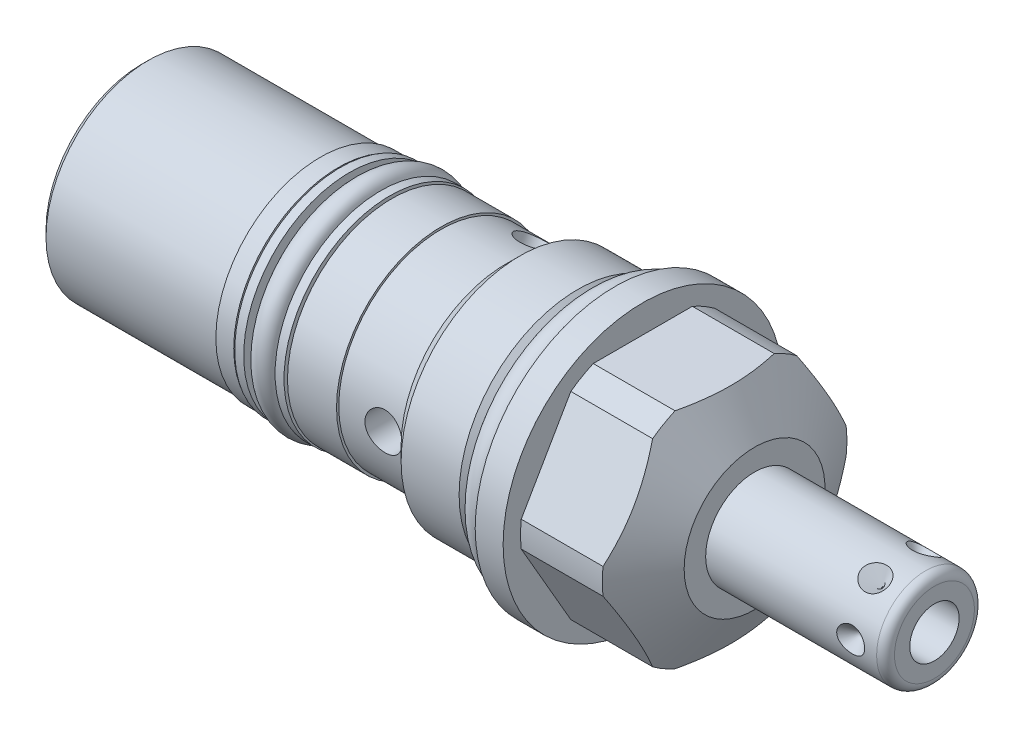
from build123d import *

# Parameters (mm, degrees)
SKETCH2_OUTSIDE_W  = 50.328
SKETCH2_OUTSIDE_H  = 50.328
CUT_EXTRUDE1_DEPTH = 12.7
CIRPATTERN1_COUNT  = 6
SKETCH6_W          = 13.716
SKETCH6_H          = 0.254
SKETCH7_R          = 0.8001
CUT_EXTRUDE2_DEPTH = 0.762
SKETCH8_W          = 6.1087
SKETCH8_H          = 2.0447
SKETCH9_W          = 1.016
SKETCH9_H          = 2.1844
SKETCH10_W         = 2.1082
SKETCH10_H         = 10.82675
CIRPATTERN2_COUNT  = 3
CHAMFER1_SIZE      = 0.762
SKETCH11_R         = 1.4732
SKETCH12_R         = 1.3081


with BuildPart() as part:
    # Sketch1 → Revolve1 (revolve)
    with BuildSketch(Plane.XY, mode=Mode.PRIVATE) as revolve1_sk:
        Polygon((0, 15.875), (3.175, 15.875), (3.175, 13.8938), (12.472790334, 13.8938), (15.875, 8.001), (15.875, 0), (-53.7972, 0), (-53.7972, 11.6205), (-12.4206, 11.6205), (-12.4206, 11.8745), (-10.80135, 13.49375), (-4.21005, 13.49375), (-2.7178, 12.0015), (0, 12.0015), align=None)
    revolve(revolve1_sk.sketch.rotate(Axis((0, 0, 0), (1, 0, 0)), 90), axis=Axis((0, 0, 0), (1, 0, 0)))  # turned: the seam where the file's is

    # Sketch2 outside → Cut-Extrude1 (cut)
    with BuildSketch(Plane(origin=(15.875, 0, 0), x_dir=(0, 0, -1), z_dir=(1, 0, 0))):
        Rectangle(SKETCH2_OUTSIDE_W, SKETCH2_OUTSIDE_H)
        Polygon((7.332348419, 12.7), (-7.332348419, 12.7), (-14.664696837, 0), (-7.332348419, -12.7), (7.332348419, -12.7), (14.664696837, 0), align=None, mode=Mode.SUBTRACT)
    extrude(amount=-CUT_EXTRUDE1_DEPTH, mode=Mode.SUBTRACT)

    # Sketch3 → Revolve2 (revolve)
    with BuildSketch(Plane.XY, mode=Mode.PRIVATE) as revolve2_sk:
        with BuildLine():
            Line((15.875, 5.55625), (35.306, 5.55625))
            ThreePointArc((35.306, 5.55625), (36.02442049, 5.25867049), (36.322, 4.54025))
            Line((36.322, 4.54025), (36.322, 0))
            Line((36.322, 0), (15.875, 0))
            Line((15.875, 0), (15.875, 5.55625))
        make_face()
    revolve(revolve2_sk.sketch.rotate(Axis((0, 0, 0), (1, 0, 0)), 90), axis=Axis((0, 0, 0), (1, 0, 0)))  # turned: the seam where the file's is

    # Sketch4 → Cut-Revolve1 (revolve, cut)
    with BuildSketch(Plane(origin=(0, 0, 0), x_dir=(1, 0, 0), z_dir=(0, 1, 0)), mode=Mode.PRIVATE) as cut_revolve1_sk:
        Polygon((33.9471, 5.55625), (32.3596, 5.55625), (32.3596, 3.96875), align=None)
    cut_revolve1 = revolve(cut_revolve1_sk.sketch.rotate(Axis((32.3596, 0, -10.073804773), (0, 0, 1)), 180), axis=Axis((32.3596, 0, -10.073804773), (0, 0, 1)), mode=Mode.SUBTRACT)  # turned: the seam where the file's is

    # CirPattern1: Cut-Revolve1 ×6 about axis
    cirpattern1_axis = Axis((0, 0, 0), (-1, 0, 0))
    for i in range(1, CIRPATTERN1_COUNT):
        add(cut_revolve1.rotate(cirpattern1_axis, i * 360 / CIRPATTERN1_COUNT), mode=Mode.SUBTRACT)

    # Sketch5 → Cut-Revolve2 (revolve, cut)
    with BuildSketch(Plane.XY, mode=Mode.PRIVATE) as cut_revolve2_sk:
        Polygon((36.322, 2.8067), (26.162, 2.8067), (24.475564501, 0), (36.322, 0), align=None)
    revolve(cut_revolve2_sk.sketch.rotate(Axis((0, 0, 0), (1, 0, 0)), 90), axis=Axis((0, 0, 0), (1, 0, 0)), mode=Mode.SUBTRACT)  # turned: the seam where the file's is

    # Sketch6 → Revolve3 (revolve)
    with BuildSketch(Plane.XY, mode=Mode.PRIVATE) as revolve3_sk:
        with Locations((-26.6192, 11.7475)):
            Rectangle(SKETCH6_W, SKETCH6_H)
    revolve(revolve3_sk.sketch.rotate(Axis((0, 0, 0), (-1, 0, 0)), 270), axis=Axis((0, 0, 0), (-1, 0, 0)))  # turned: the seam where the file's is

    # Sketch7 → Cut-Extrude2 (cut)
    with BuildSketch(Plane.ZY.offset(53.7972)):
        Circle(SKETCH7_R)
    extrude(amount=-CUT_EXTRUDE2_DEPTH, mode=Mode.SUBTRACT)

    # Sketch8 → Cut-Revolve3 (revolve, cut)
    with BuildSketch(Plane.XY, mode=Mode.PRIVATE) as cut_revolve3_sk:
        with Locations((-28.39085, 10.85215)):
            Rectangle(SKETCH8_W, SKETCH8_H)
    revolve(cut_revolve3_sk.sketch.rotate(Axis((0, 0, 0), (-1, 0, 0)), 270), axis=Axis((0, 0, 0), (-1, 0, 0)), mode=Mode.SUBTRACT)  # turned: the seam where the file's is

    # Sketch9 → Revolve4 (revolve)
    with BuildSketch(Plane.XY, mode=Mode.PRIVATE) as revolve4_sk:
        with Locations((-26.0985, 10.922)):
            Rectangle(SKETCH9_W, SKETCH9_H)
        with Locations((-30.6832, 10.922)):
            Rectangle(SKETCH9_W, SKETCH9_H)
    revolve(revolve4_sk.sketch.rotate(Axis((0, 0, 0), (-1, 0, 0)), 270), axis=Axis((0, 0, 0), (-1, 0, 0)))  # turned: the seam where the file's is

    # Sketch10 → Cut-Revolve4 (revolve, cut)
    with BuildSketch(Plane(origin=(0, 0, 0), x_dir=(1, 0, 0), z_dir=(0, 1, 0))):
        with Locations((-15.7353, -6.207125)):
            Rectangle(SKETCH10_W, SKETCH10_H)
    cut_revolve4 = revolve(axis=Axis((-14.6812, 0, -23.036850257), (0, 0, 1)), mode=Mode.SUBTRACT)

    # CirPattern2: Cut-Revolve4 ×3 about axis
    cirpattern2_axis = Axis((0, 0, 0), (1, 0, 0))
    for i in range(1, CIRPATTERN2_COUNT):
        add(cut_revolve4.rotate(cirpattern2_axis, i * 360 / CIRPATTERN2_COUNT), mode=Mode.SUBTRACT)

    # Chamfer1
    chamfer1_edges = [part.edges().sort_by_distance(p)[0] for p in [
        (-53.7972, 0, -11.6205),
    ]]
    chamfer(chamfer1_edges, length=CHAMFER1_SIZE)


with BuildPart() as body_2:
    # Sketch11 → Revolve5 (revolve)
    with BuildSketch(Plane.XY, mode=Mode.PRIVATE) as revolve5_sk:
        with Locations((-1.4732, 13.4747)):
            Circle(SKETCH11_R)
    revolve(revolve5_sk.sketch.rotate(Axis((0, 0, 0), (1, 0, 0)), 90), axis=Axis((0, 0, 0), (1, 0, 0)))  # turned: the seam where the file's is


with BuildPart() as body_3:
    # Sketch12 → Revolve7 (revolve)
    with BuildSketch(Plane.XY, mode=Mode.PRIVATE) as revolve7_sk:
        with Locations((-28.39085, 11.1379)):
            Circle(SKETCH12_R)
    revolve(revolve7_sk.sketch.rotate(Axis((0, 0, 0), (-1, 0, 0)), 270), axis=Axis((0, 0, 0), (-1, 0, 0)))  # turned: the seam where the file's is


solid = Compound([part.part, body_2.part, body_3.part])
